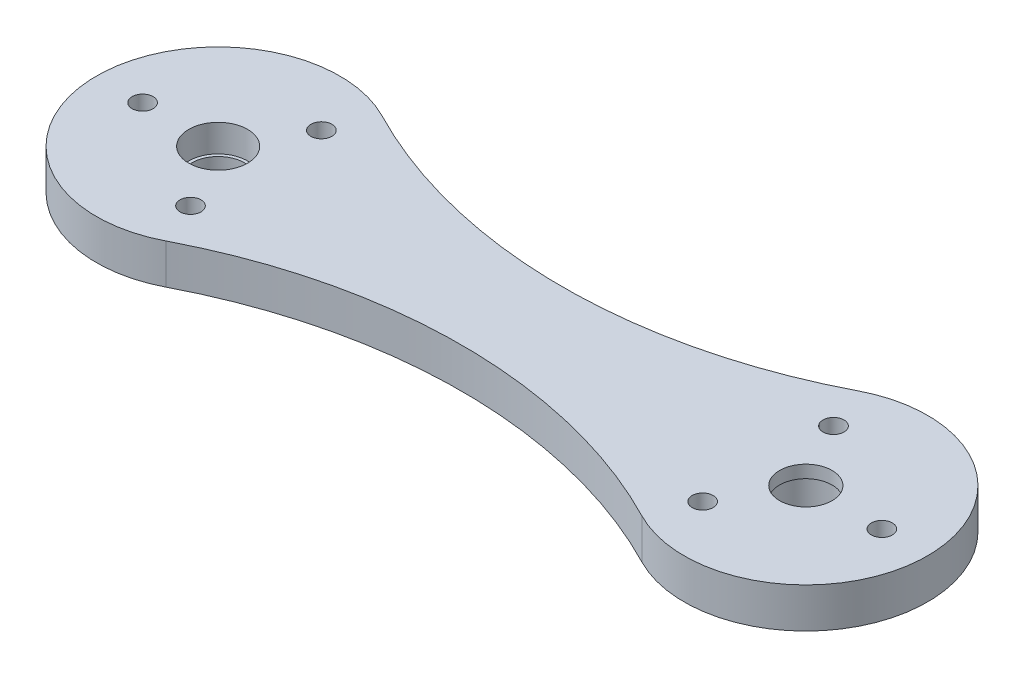
from build123d import *

# Parameters (mm, degrees)
BOSS_EXTRUDE1_DEPTH   = 4.7625
SKETCH2_R             = 3.5
CUT_EXTRUDE1_DEPTH    = 3.2625
SKETCH3_R             = 3.125
CUT_EXTRUDE2_DEPTH    = 2.5
SKETCH6_R             = 3.125
CUT_EXTRUDE5_DEPTH    = 5.7625
SKETCH7_R             = 3.5
CUT_EXTRUDE6_DEPTH    = 3.2625
M3X0_5_TAPPED_HOLE1_D = 2.5
M3X0_5_TAPPED_HOLE2_D = 2.5


with BuildPart() as part:
    # Sketch1 → Boss-Extrude1 (new body)
    with BuildSketch(Plane(origin=(0, 0, 0), x_dir=(1, 0, 0), z_dir=(0, 1, 0))):
        with BuildLine():
            ThreePointArc((-28.349392947, 12.884852573), (-49.5, 0), (-28.349392947, -12.884852573))
            ThreePointArc((-28.349392947, -12.884852573), (0, -6), (28.349392947, -12.884852573))
            ThreePointArc((28.349392947, -12.884852573), (49.5, 0), (28.349392947, 12.884852573))
            ThreePointArc((28.349392947, 12.884852573), (0, 6), (-28.349392947, 12.884852573))
        make_face()
    extrude(amount=BOSS_EXTRUDE1_DEPTH)

    # Sketch2 → Cut-Extrude1 (cut)
    with BuildSketch(Plane(origin=(0, 4.7625, 0), x_dir=(1, 0, 0), z_dir=(0, 1, 0))):
        with Locations((-35, 0)):
            Circle(SKETCH2_R)
    extrude(amount=-CUT_EXTRUDE1_DEPTH, mode=Mode.SUBTRACT)

    # Sketch3 → Cut-Extrude2 (cut, through all)
    with BuildSketch(Plane(origin=(0, 1.5, 0), x_dir=(1, 0, 0), z_dir=(0, 1, 0))):
        with Locations((-35, 0)):
            Circle(SKETCH3_R)
    extrude(amount=-CUT_EXTRUDE2_DEPTH, mode=Mode.SUBTRACT)

    # Sketch6 → Cut-Extrude5 (cut, through all)
    with BuildSketch(Plane.XZ):
        with Locations((35, 0)):
            Circle(SKETCH6_R)
    extrude(amount=-CUT_EXTRUDE5_DEPTH, mode=Mode.SUBTRACT)

    # Sketch7 → Cut-Extrude6 (cut)
    with BuildSketch(Plane.XZ):
        with Locations((35, 0)):
            Circle(SKETCH7_R)
    extrude(amount=-CUT_EXTRUDE6_DEPTH, mode=Mode.SUBTRACT)

    # M3x0.5 Tapped Hole1 (through all)
    with Locations(Plane(origin=(0, 4.7625, 0), x_dir=(-1, 0, 0), z_dir=(0, 1, 0))):
        with Locations((30.5, 7.794228634), (44, 0), (30.5, -7.794228634)):
            Hole(M3X0_5_TAPPED_HOLE1_D / 2)

    # M3x0.5 Tapped Hole2 (through all)
    with Locations(Plane.XZ):
        with Locations((43.999848922, -0.052147689), (30.5, 7.794228634), (30.5, -7.794228634)):
            Hole(M3X0_5_TAPPED_HOLE2_D / 2)


solid = part.part
